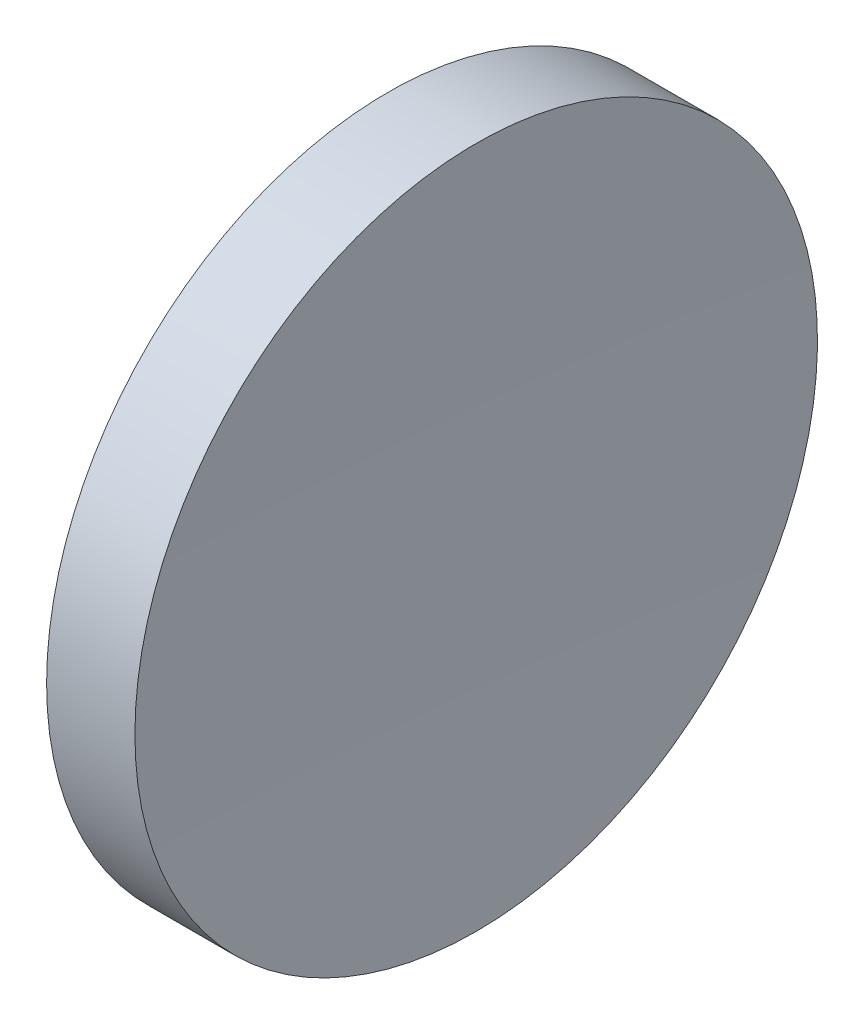
from build123d import *


with BuildPart() as part:
    # 草图1 → 旋转1 (revolve)
    with BuildSketch(Plane.XY, mode=Mode.PRIVATE) as revolve_1_sk:
        with BuildLine():
            Line((230.199611905, 138.756042247), (230.199611905, 176.256042247))
            Line((230.199611905, 176.256042247), (239.90298428, 176.256042247))
            ThreePointArc((239.90298428, 176.256042247), (239.375470468, 157.509340175), (239.199611914, 138.756042247))
            Line((239.199611914, 138.756042247), (230.199611905, 138.756042247))
        make_face()
    revolve(revolve_1_sk.sketch.rotate(Axis((217.970286004, 138.756042247, 0), (1, 0, 0)), 180), axis=Axis((217.970286004, 138.756042247, 0), (1, 0, 0)))  # turned: the seam where the file's is


solid = part.part
